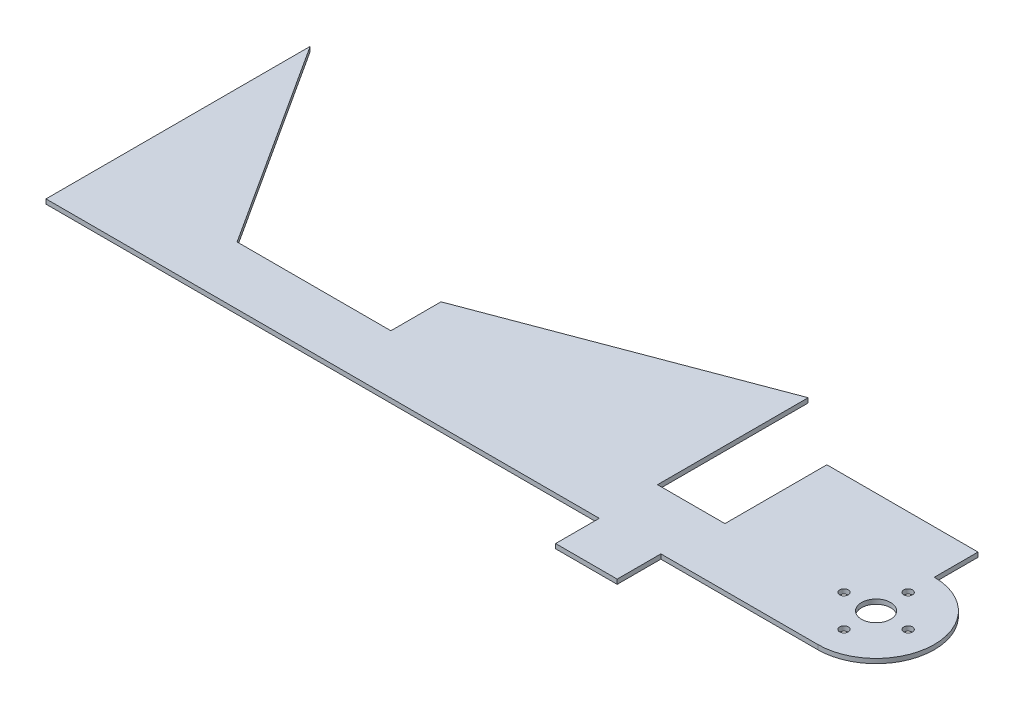
from build123d import *

# Parameters (mm, degrees)
BOSS_EXTRUDE2_DEPTH     = 1.000000032
BOSS_EXTRUDE4_DEPTH     = 1.000000032
SKETCH4_R               = 3.175
SKETCH4_R_2             = 0.950000005
CUT_EXTRUDE1_DEPTH      = 1
CUT_EXTRUDE1_DEPTH_BACK = 2.000000032
SKETCH6_W               = 13.430000064
SKETCH6_H               = 9.525
SKETCH6_W_2             = 32.960056
BOSS_EXTRUDE5_DEPTH     = 1.000000032
CUT_EXTRUDE2_DEPTH      = 1
CUT_EXTRUDE2_DEPTH_BACK = 2.000000032


with BuildPart() as part:
    # Sketch2 → Boss-Extrude2 (new body)
    with BuildSketch(Plane(origin=(0, 0, 0), x_dir=(1, 0, 0), z_dir=(0, 1, 0))):
        Polygon((-31.351491175, -35.060458992), (-60.325, 9.840821613), (-60.325, -47.760458992), (0, -47.760458992), (60.325, -47.760458992), (60.325, -2.200955885), (-26.791523135, -35.060458992), align=None)
    extrude(amount=BOSS_EXTRUDE2_DEPTH)

    # Sketch5 → Boss-Extrude4 (add)
    with BuildSketch(Plane(origin=(0, 0, 0), x_dir=(1, 0, 0), z_dir=(0, 1, 0))):
        with BuildLine():
            Line((60.325, -47.760458992), (75.025000064, -47.760458992))
            Line((75.025000064, -47.760458992), (107.985056064, -47.760458992))
            ThreePointArc((107.985056064, -47.760458992), (120.685056064, -35.060458992), (107.985056064, -22.360458992))
            Line((107.985056064, -22.360458992), (75.025000064, -22.360458992))
            Line((75.025000064, -22.360458992), (75.025000064, -35.060458992))
            Line((75.025000064, -35.060458992), (60.325, -35.060458992))
            Line((60.325, -35.060458992), (60.325, -47.760458992))
        make_face()
    extrude(amount=BOSS_EXTRUDE4_DEPTH)

    # Sketch4 → Cut-Extrude1 (cut, two sides)
    with BuildSketch(Plane(origin=(0, 1.000000032, 0), x_dir=(1, 0, 0), z_dir=(0, 1, 0))) as cut_extrude1_sk:
        with Locations((107.985056064, -35.060458992)):
            Circle(SKETCH4_R)
        with Locations((107.985056064, -42.060458962)):
            Circle(SKETCH4_R_2)
        with Locations((107.985056064, -28.060459022)):
            Circle(SKETCH4_R_2)
        with Locations((100.985056094, -35.060458992)):
            Circle(SKETCH4_R_2)
        with Locations((114.985056034, -35.060458992)):
            Circle(SKETCH4_R_2)
    extrude(amount=CUT_EXTRUDE1_DEPTH, mode=Mode.SUBTRACT)
    extrude(cut_extrude1_sk.sketch, amount=-CUT_EXTRUDE1_DEPTH_BACK, mode=Mode.SUBTRACT)

    # Sketch6 → Boss-Extrude5 (add)
    with BuildSketch(Plane(origin=(0, 1.000000032, 0), x_dir=(1, 0, 0), z_dir=(0, 1, 0))):
        with Locations((67.040000032, -52.522958992)):
            Rectangle(SKETCH6_W, SKETCH6_H)
        with Locations((91.505028064, -17.597958992)):
            Rectangle(SKETCH6_W_2, SKETCH6_H)
    extrude(amount=-BOSS_EXTRUDE5_DEPTH)

    # Sketch8 → Cut-Extrude2 (cut, two sides)
    with BuildSketch(Plane(origin=(0, 1.000000032, 0), x_dir=(1, 0, 0), z_dir=(0, 1, 0))) as cut_extrude2_sk:
        Polygon((-26.791523135, -35.060458992), (2.18198569, -24.131933967), (2.18198569, -35.060458992), align=None)
    extrude(amount=CUT_EXTRUDE2_DEPTH, mode=Mode.SUBTRACT)
    extrude(cut_extrude2_sk.sketch, amount=-CUT_EXTRUDE2_DEPTH_BACK, mode=Mode.SUBTRACT)


solid = part.part
